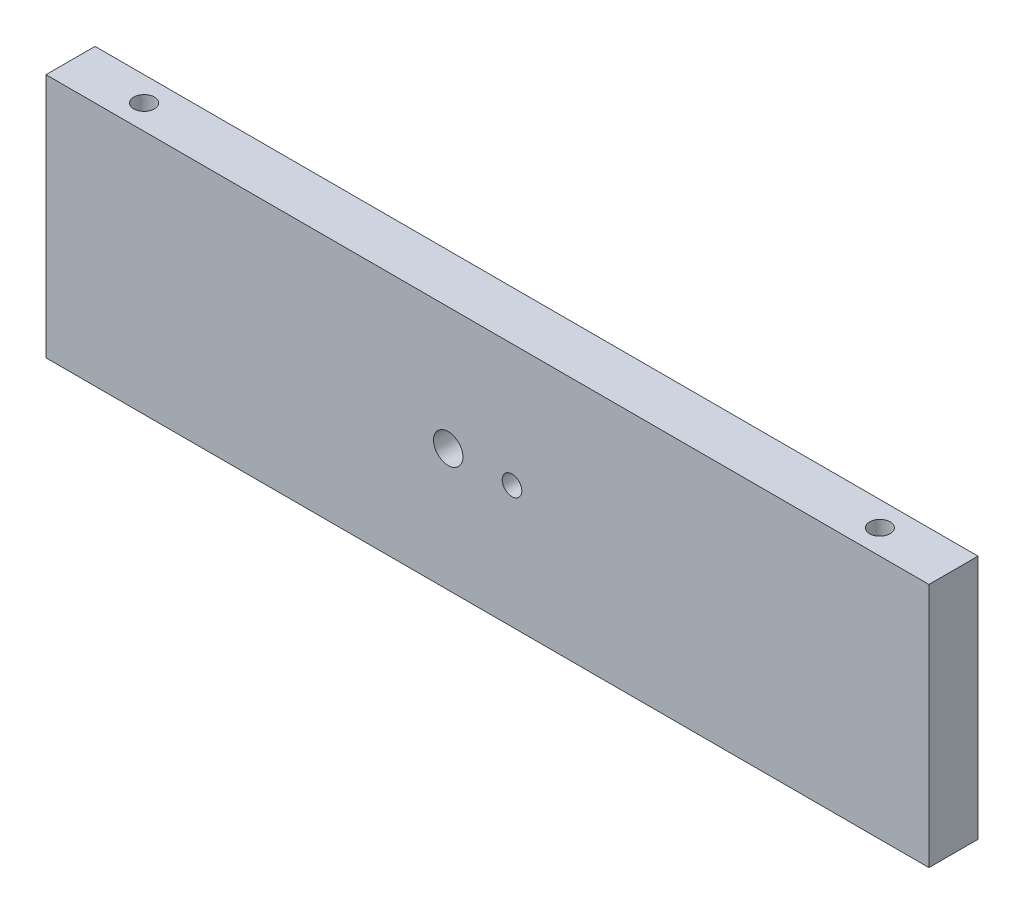
from build123d import *

# Parameters (mm, degrees)
SKETCH2_W             = 180
SKETCH2_H             = 50
BOSS_EXTRUDE1_DEPTH   = 10
SKETCH6_R             = 3
CUT_EXTRUDE1_DEPTH    = 10
M5_TAPPED_HOLE2_D     = 4.2
M5_TAPPED_HOLE2_DEPTH = 14
M5_TAPPED_HOLE2_TIP   = 1.2618073
SKETCH9_R             = 2
CUT_EXTRUDE2_DEPTH    = 10


with BuildPart() as part:
    # Sketch2 → Boss-Extrude1 (new body)
    with BuildSketch(Plane.XY):
        Rectangle(SKETCH2_W, SKETCH2_H)
    extrude(amount=BOSS_EXTRUDE1_DEPTH)

    # Sketch6 → Cut-Extrude1 (cut)
    with BuildSketch(Plane.XY.offset(10)):
        with Locations((-8, 0)):
            Circle(SKETCH6_R)
    extrude(amount=-CUT_EXTRUDE1_DEPTH, mode=Mode.SUBTRACT)

    # M5 Tapped Hole2
    with Locations(Plane(origin=(0, 25, 0), x_dir=(1, 0, 0), z_dir=(0, 1, 0))):
        with Locations((-75, -5), (75, -5)):
            Hole(M5_TAPPED_HOLE2_D / 2, depth=M5_TAPPED_HOLE2_DEPTH)
            with Locations((0, 0, -(M5_TAPPED_HOLE2_DEPTH + M5_TAPPED_HOLE2_TIP / 2))):  # 118° drill point
                Cone(0, M5_TAPPED_HOLE2_D / 2, M5_TAPPED_HOLE2_TIP, mode=Mode.SUBTRACT)

    # Sketch9 → Cut-Extrude2 (cut)
    with BuildSketch(Plane.XY.offset(10)):
        with Locations((5, 0)):
            Circle(SKETCH9_R)
    extrude(amount=-CUT_EXTRUDE2_DEPTH, mode=Mode.SUBTRACT)


solid = part.part
